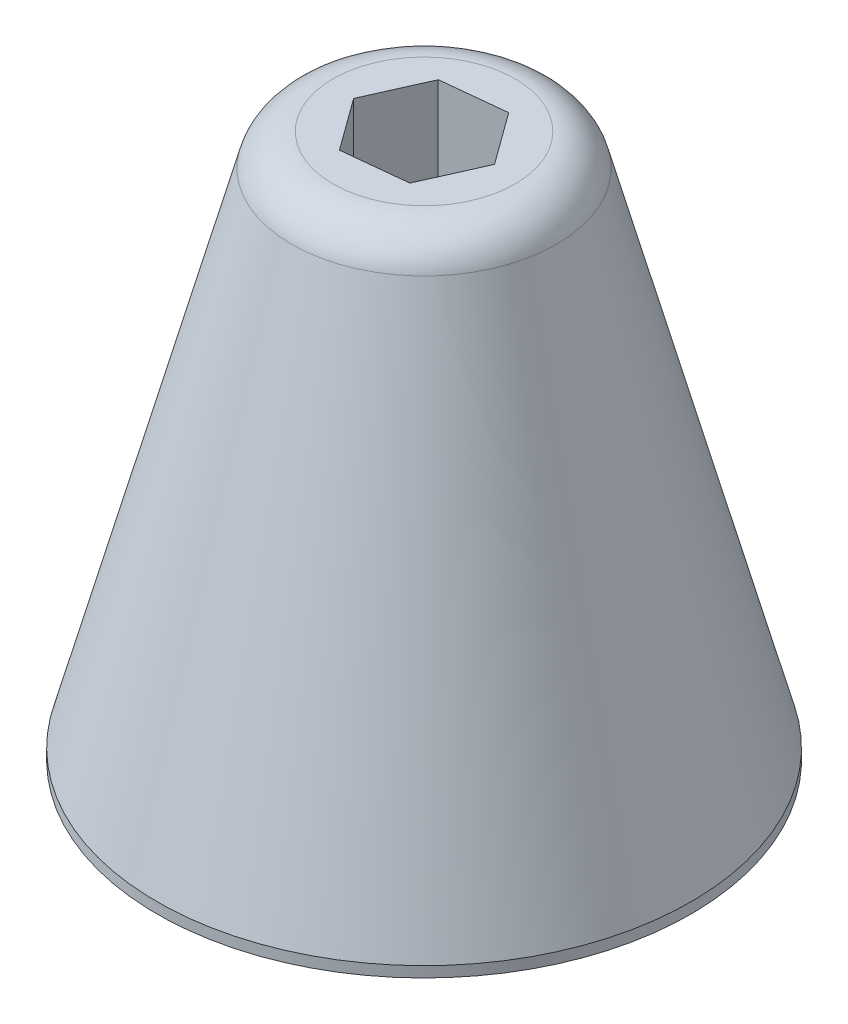
from build123d import *

# Parameters (mm, degrees)
SKETCH2_R               = 31.75
BOSS_EXTRUDE1_DEPTH     = 63.5
BOSS_EXTRUDE1_TAPER     = 15
SKETCH3_R               = 31.75
BOSS_EXTRUDE2_DEPTH     = 1.27
CUT_EXTRUDE2_DEPTH      = 64.5000001
CUT_EXTRUDE2_DEPTH_BACK = 2.27
FILLET1_R               = 5.08


with BuildPart() as part:
    # Sketch2 → Boss-Extrude1 (new body)
    with BuildSketch(Plane(origin=(0, 0, 0), x_dir=(1, 0, 0), z_dir=(0, 1, 0))):
        Circle(SKETCH2_R)
    extrude(amount=BOSS_EXTRUDE1_DEPTH, taper=BOSS_EXTRUDE1_TAPER)

    # Sketch3 → Boss-Extrude2 (add)
    with BuildSketch(Plane.XZ):
        Circle(SKETCH3_R)
    extrude(amount=BOSS_EXTRUDE2_DEPTH)

    # Sketch7 → Cut-Extrude2 (cut, two sides)
    with BuildSketch(Plane(origin=(0, 0, 0), x_dir=(1, 0, 0), z_dir=(0, 1, 0))) as cut_extrude2_sk:
        Polygon((4.482800658, -6.168866962), (7.583795831, 0.79778577), (3.100995172, 6.966652731), (-4.482800658, 6.168866962), (-7.583795831, -0.79778577), (-3.100995172, -6.966652731), align=None)
    extrude(amount=CUT_EXTRUDE2_DEPTH, mode=Mode.SUBTRACT)
    extrude(cut_extrude2_sk.sketch, amount=-CUT_EXTRUDE2_DEPTH_BACK, mode=Mode.SUBTRACT)

    # Fillet1
    fillet1_edges = [part.edges().sort_by_distance(p)[0] for p in [
        (-14.735226281, 63.5, 0),
    ]]
    fillet(fillet1_edges, radius=FILLET1_R)


solid = part.part
